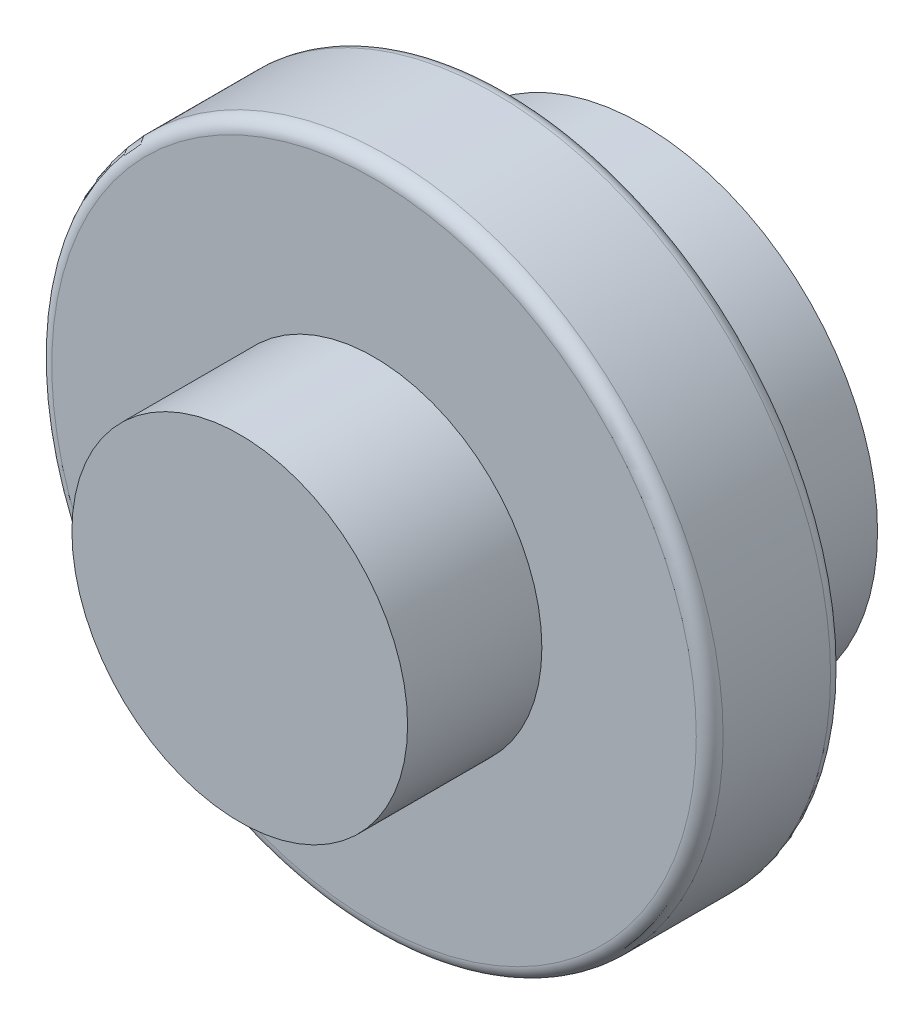
from build123d import *

# Parameters (mm, degrees)
SKETCH1_R           = 17.5
BOSS_EXTRUDE1_DEPTH = 10
SKETCH2_R           = 25
BOSS_EXTRUDE2_DEPTH = 10
SKETCH3_R           = 12.5
BOSS_EXTRUDE3_DEPTH = 10
FILLET1_R           = 1


with BuildPart() as part:
    # Sketch1 → Boss-Extrude1 (new body)
    with BuildSketch(Plane.XY):
        Circle(SKETCH1_R)
    extrude(amount=BOSS_EXTRUDE1_DEPTH)

    # Sketch2 → Boss-Extrude2 (add)
    with BuildSketch(Plane.XY.offset(10)):
        Circle(SKETCH2_R)
    extrude(amount=BOSS_EXTRUDE2_DEPTH)

    # Sketch3 → Boss-Extrude3 (add)
    with BuildSketch(Plane.XY.offset(20)):
        Circle(SKETCH3_R)
    extrude(amount=BOSS_EXTRUDE3_DEPTH)

    # Fillet1
    fillet1_edges = [part.edges().sort_by_distance(p)[0] for p in [
        (-25, 0, 10),
        (-25, 0, 20),
    ]]
    fillet(fillet1_edges, radius=FILLET1_R)


solid = part.part
